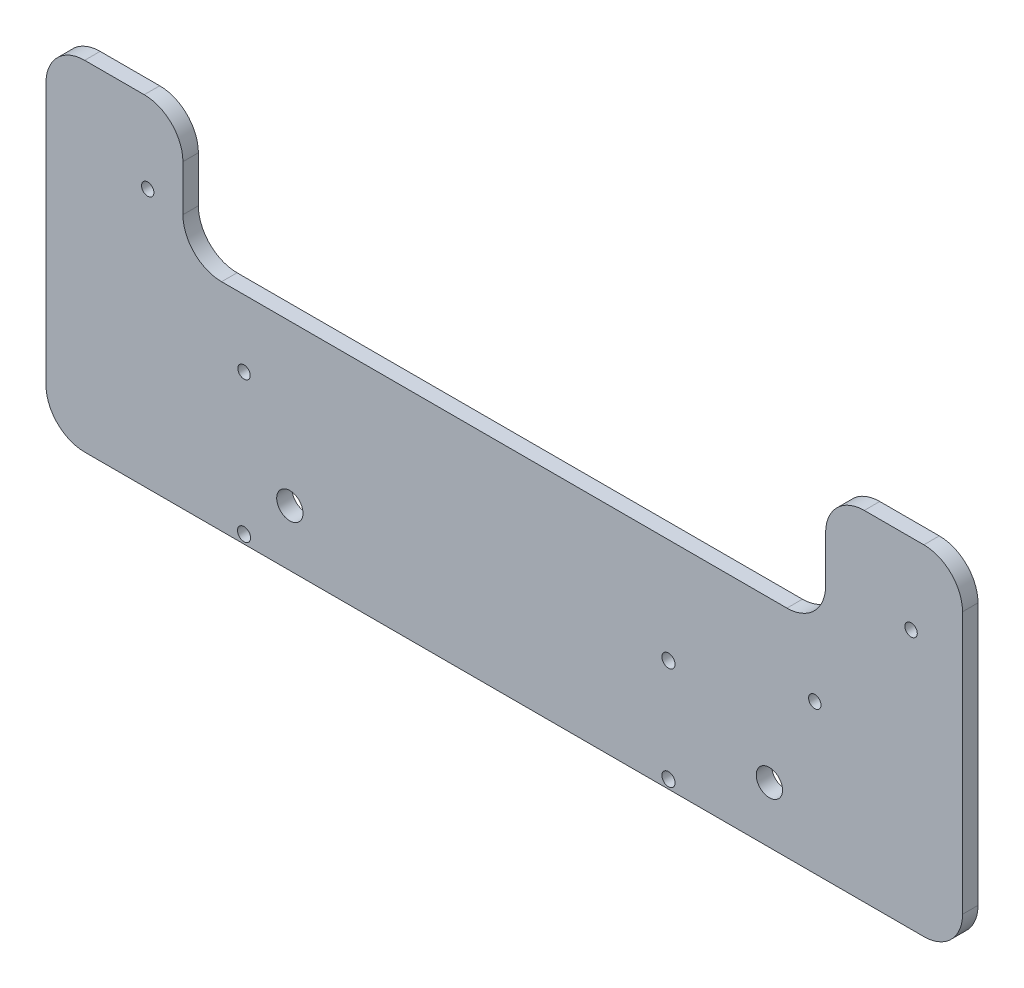
from build123d import *

# Parameters (mm, degrees)
BOSS_EXTRUDE1_DEPTH     = 4
M3_CLEARANCE_HOLE1_D    = 3.2
FILLET1_R               = 10
TAP_DRILL_FOR_M8_TAP1_D = 6.8
M3_CLEARANCE_HOLE3_D    = 3.4


with BuildPart() as part:
    # Sketch1 → Boss-Extrude1 (new body)
    with BuildSketch(Plane.XY):
        Polygon((128.627293893, -305.665681156), (128.627293893, -359.464720764), (-108.372706107, -359.464720764), (-108.372706107, -305.665681156), (-108.372706107, -271.718782294), (-72.968170503, -271.718782294), (-72.968170503, -303.597286204), (93.222758289, -303.597286204), (93.222758289, -271.718782294), (128.627293893, -271.718782294), align=None)
    extrude(amount=BOSS_EXTRUDE1_DEPTH)

    # M3 Clearance Hole1 (through all)
    with Locations(Plane.XY.offset(4)):
        with Locations((-82.072706107, -292.415681156), (115.327293893, -292.415681156), (90.417293893, -320.915681156), (-57.162706107, -320.915681156)):
            Hole(M3_CLEARANCE_HOLE1_D / 2)

    # Fillet1
    fillet1_edges = [part.edges().sort_by_distance(p)[0] for p in [
        (128.627293893, -359.464720764, 2),
        (-108.372706107, -359.464720764, 2),
        (-108.372706107, -271.718782294, 2),
        (-72.968170503, -271.718782294, 2),
        (-72.968170503, -303.597286204, 2),
        (93.222758289, -303.597286204, 2),
        (93.222758289, -271.718782294, 2),
        (128.627293893, -271.718782294, 2),
    ]]
    fillet(fillet1_edges, radius=FILLET1_R)

    # Tap Drill for M8 Tap1 (through all)
    with Locations(Plane.XY.offset(4)):
        with Locations((78.681014792, -344.935502047), (-45.318985208, -344.935502047)):
            Hole(TAP_DRILL_FOR_M8_TAP1_D / 2)

    # M3 Clearance Hole3 (through all)
    with Locations(Plane.XY.offset(4)):
        with Locations((52.592509681, -330.665681156), (52.592509681, -357.226830961), (-57.162706107, -357.226830961)):
            Hole(M3_CLEARANCE_HOLE3_D / 2)


solid = part.part
